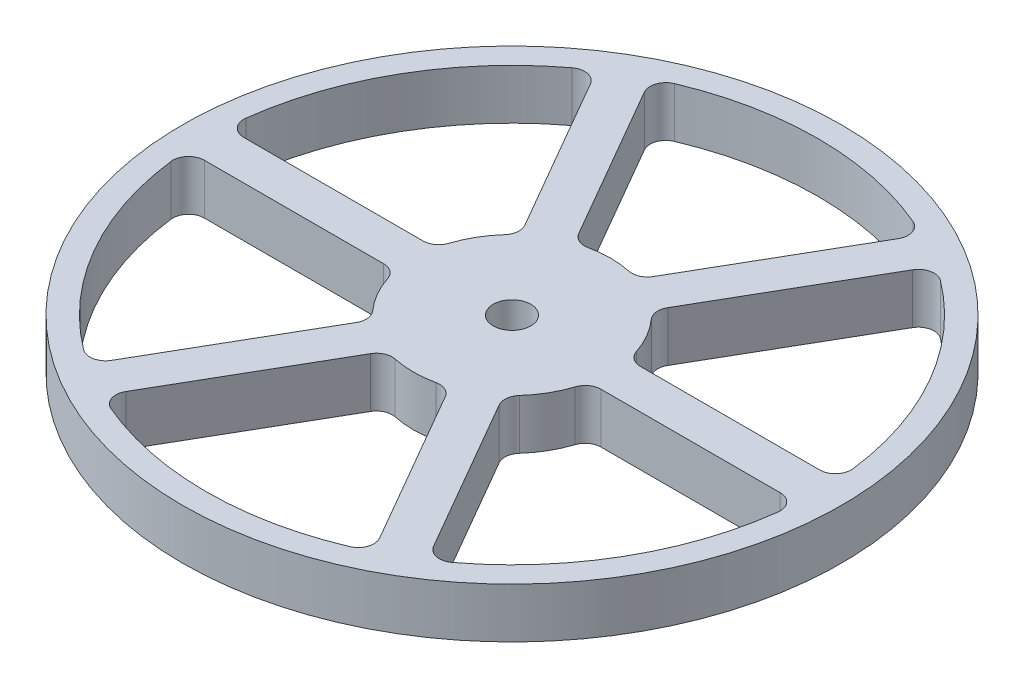
from build123d import *

# Parameters (mm, degrees)
SKETCH2_W                    = 82.55
SKETCH2_H                    = 12.7
CUT_EXTRUDE1_DEPTH           = 13.7
FILLET1_R                    = 4
CIRPATTERN4_COUNT            = 6
FILLET1_OF_CIRPATTERN4_R     = 4
CHAMFER2_SIZE                = 1
F_3_8_0_375_DIAMETER_HOLE1_D = 9.525
SKETCH12_R                   = 83.55
SKETCH12_R_2                 = 82.55
BOSS_EXTRUDE1_DEPTH          = 12.7


with BuildPart() as part:
    # Sketch2 → Revolve1 (revolve)
    with BuildSketch(Plane(origin=(0, 0, 0), x_dir=(0, 0, -1), z_dir=(1, 0, 0))):
        with Locations((-41.275, 6.35)):
            Rectangle(SKETCH2_W, SKETCH2_H)
    revolve(axis=Axis((0, -0.75, 0), (0, 1, 0)))

    # Sketch8 → Cut-Extrude1 (cut, through all)
    with BuildSketch(Plane(origin=(0, 12.7, 0), x_dir=(1, 0, 0), z_dir=(0, 1, 0))):
        with BuildLine():
            Line((-7.917322, 23.713203), (-34.364196, 69.520533))
            ThreePointArc((-34.364196, 69.520533), (0, 77.55), (34.364196, 69.520533))
            Line((34.364196, 69.520533), (7.917322, 23.713203))
            ThreePointArc((7.917322, 23.713203), (0, 25), (-7.917322, 23.713203))
        make_face()
    cut_extrude1 = extrude(amount=-CUT_EXTRUDE1_DEPTH, mode=Mode.SUBTRACT)

    # Fillet1
    fillet1_edges = [part.edges().sort_by_distance(p)[0] for p in [
        (7.917322, 6.35, -23.713203),
        (-7.917322, 6.35, -23.713203),
        (-34.364196, 6.35, -69.520533),
        (34.364196, 6.35, -69.520533),
    ]]
    fillet(fillet1_edges, radius=FILLET1_R)

    # CirPattern4: Cut-Extrude1 ×6 about axis
    cirpattern4_axis = Axis((0, 0, 0), (0, 1, 0))
    for i in range(1, CIRPATTERN4_COUNT):
        add(cut_extrude1.rotate(cirpattern4_axis, i * 360 / CIRPATTERN4_COUNT), mode=Mode.SUBTRACT)

    # Fillet1 of CirPattern4
    fillet1_of_cirpattern4_edges = [part.edges().sort_by_distance(p)[0] for p in [
        (-16.577576, 6.35, -18.713203),
        (-24.494897, 6.35, -5),
        (-77.388646, 6.35, -5),
        (-43.02445, 6.35, -64.520533),
        (-24.494897, 6.35, 5),
        (-16.577576, 6.35, 18.713203),
        (-43.02445, 6.35, 64.520533),
        (-77.388646, 6.35, 5),
        (-7.917322, 6.35, 23.713203),
        (7.917322, 6.35, 23.713203),
        (34.364196, 6.35, 69.520533),
        (-34.364196, 6.35, 69.520533),
        (16.577576, 6.35, 18.713203),
        (24.494897, 6.35, 5),
        (77.388646, 6.35, 5),
        (43.02445, 6.35, 64.520533),
        (24.494897, 6.35, -5),
        (16.577576, 6.35, -18.713203),
        (43.02445, 6.35, -64.520533),
        (77.388646, 6.35, -5),
    ]]
    fillet(fillet1_of_cirpattern4_edges, radius=FILLET1_OF_CIRPATTERN4_R)

    # Chamfer2
    chamfer2_edges = [part.edges().sort_by_distance(p)[0] for p in [
        (0, 0, -82.55),
    ]]
    chamfer(chamfer2_edges, length=CHAMFER2_SIZE)

    # 3/8 (0.375) Diameter Hole1 (through all)
    with Locations(Plane(origin=(0, 0, 0), x_dir=(-1, 0, 0), z_dir=(0, -1, 0))):
        with Locations((0, 0)):
            Hole(F_3_8_0_375_DIAMETER_HOLE1_D / 2)

    # Sketch12 → Boss-Extrude1 (add)
    with BuildSketch(Plane(origin=(0, 12.7, 0), x_dir=(1, 0, 0), z_dir=(0, 1, 0))):
        Circle(SKETCH12_R)
        Circle(SKETCH12_R_2, mode=Mode.SUBTRACT)
    extrude(amount=-BOSS_EXTRUDE1_DEPTH)


solid = part.part
